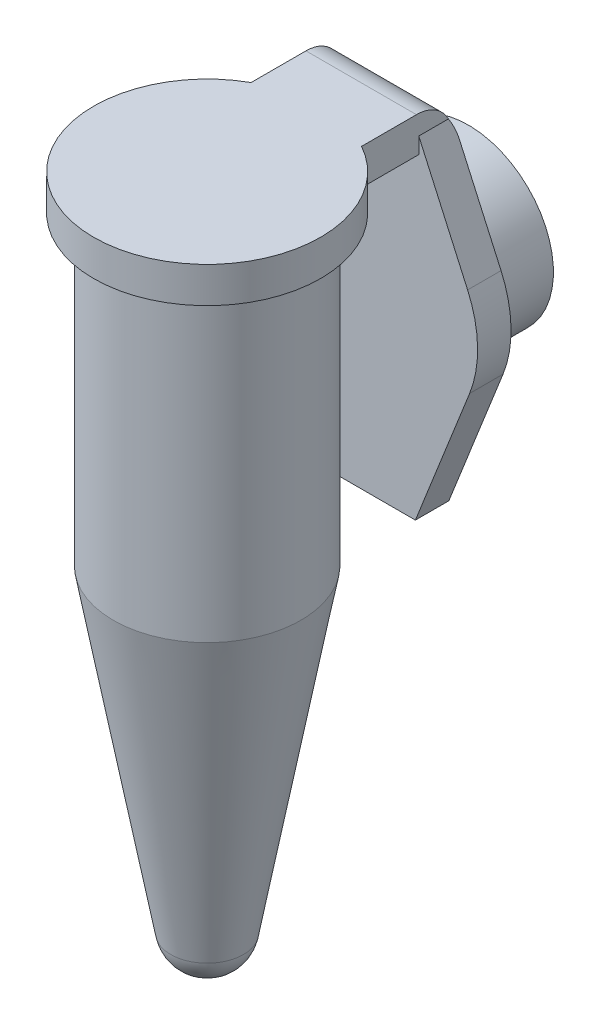
from build123d import *

# Parameters (mm, degrees)
SKETCH2_W           = 6.18
SKETCH2_H           = 3.2
BOSS_EXTRUDE1_DEPTH = 2
BOSS_EXTRUDE2_DEPTH = 1.87
SKETCH4_R           = 4.75
SKETCH4_R_2         = 3
BOSS_EXTRUDE3_DEPTH = 4
FILLET1_R           = 2


with BuildPart() as part:
    # Sketch1 → Revolve1 (revolve)
    with BuildSketch(Plane.XY):
        with BuildLine():
            Line((5.25, 36.6), (5.25, 19.5))
            Line((5.25, 19.5), (2.034602195, 1.7))
            ThreePointArc((2.034602195, 1.7), (1.325670217, 0.480936184), (0, 0))
            Line((0, 0), (0, 38.6))
            Line((0, 38.6), (6.35, 38.6))
            Line((6.35, 38.6), (6.35, 36.6))
            Line((6.35, 36.6), (5.25, 36.6))
        make_face()
    revolve(axis=Axis((0, 0, 0), (0, 1, 0)))

    # Sketch2 → Boss-Extrude1 (add)
    with BuildSketch(Plane(origin=(0, 38.6, 0), x_dir=(1, 0, 0), z_dir=(0, 1, 0))):
        with Locations((0, 7.147467891)):
            Rectangle(SKETCH2_W, SKETCH2_H)
    extrude(amount=-BOSS_EXTRUDE1_DEPTH)

    # Sketch3 → Boss-Extrude2 (add)
    with BuildSketch(Plane(origin=(0, 0, -8.747467891), x_dir=(-1, 0, 0), z_dir=(0, 0, -1))):
        with BuildLine():
            Line((-2.9, 18.8), (2.9, 18.8))
            Line((2.9, 18.8), (5.931288007, 26.449633522))
            ThreePointArc((5.931288007, 26.449633522), (6.37843004, 28.941528165), (5.821199394, 31.411137227))
            Line((5.821199394, 31.411137227), (3.09, 37.5))
            Line((3.09, 37.5), (3.09, 38.6))
            Line((3.09, 38.6), (-3.09, 38.6))
            Line((-3.09, 38.6), (-3.09, 37.5))
            Line((-3.09, 37.5), (-5.821199394, 31.411137227))
            ThreePointArc((-5.821199394, 31.411137227), (-6.37843004, 28.941528165), (-5.931288007, 26.449633522))
            Line((-5.931288007, 26.449633522), (-2.9, 18.8))
        make_face()
    extrude(amount=BOSS_EXTRUDE2_DEPTH)

    # Sketch4 → Boss-Extrude3 (add)
    with BuildSketch(Plane(origin=(0, 0, -10.617467891), x_dir=(-1, 0, 0), z_dir=(0, 0, -1))):
        with Locations((0, 28.8)):
            Circle(SKETCH4_R)
        with Locations((0, 28.8)):
            Circle(SKETCH4_R_2, mode=Mode.SUBTRACT)
    extrude(amount=BOSS_EXTRUDE3_DEPTH)

    # Fillet1
    fillet1_edges = [part.edges().sort_by_distance(p)[0] for p in [
        (0, 38.6, -10.617467891),
    ]]
    fillet(fillet1_edges, radius=FILLET1_R)


solid = part.part
